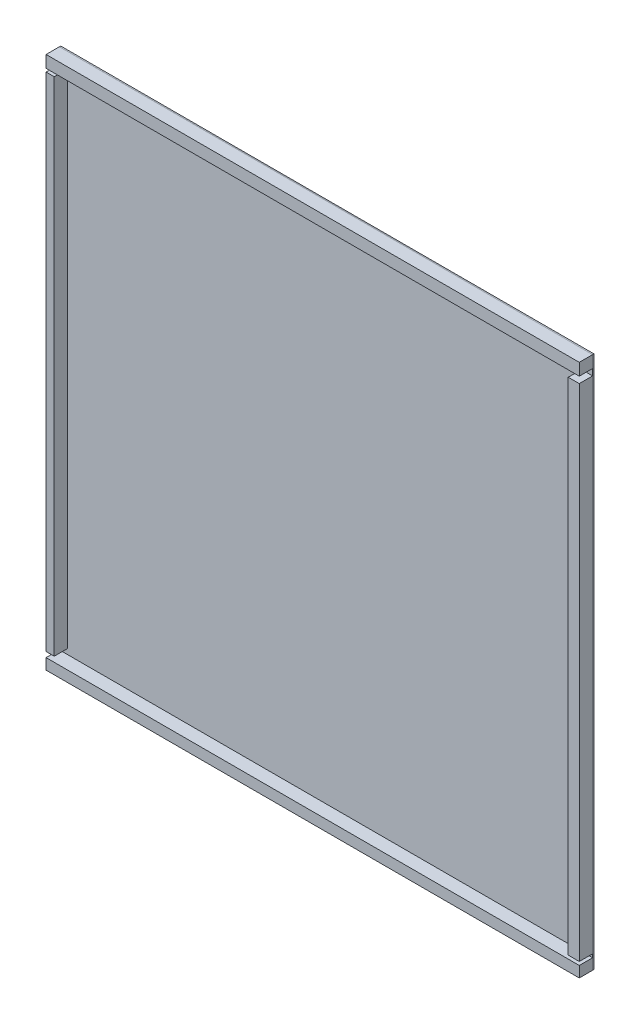
from build123d import *

# Parameters (mm, degrees)
SKETCH1_W           = 4000
SKETCH1_H           = 4000
BOSS_EXTRUDE1_DEPTH = 10
SKETCH2_W           = 4000
SKETCH2_H           = 4000
BOSS_EXTRUDE2_DEPTH = 10
SKETCH3_W           = 4000
SKETCH3_H           = 90.124072545
BOSS_EXTRUDE3_DEPTH = 100
SKETCH4_W           = 4000
SKETCH4_H           = 81.585108981
BOSS_EXTRUDE4_DEPTH = 100
SKETCH5_W           = 82.704697277
SKETCH5_H           = 3754.532371486
BOSS_EXTRUDE5_DEPTH = 100
SKETCH6_W           = 61.008409113
SKETCH6_H           = 3764.829598476
BOSS_EXTRUDE6_DEPTH = 100


with BuildPart() as part:
    # Sketch1 → Boss-Extrude1 (new body)
    with BuildSketch(Plane.XY):
        with Locations((1750, 1750)):
            Rectangle(SKETCH1_W, SKETCH1_H)
    extrude(amount=BOSS_EXTRUDE1_DEPTH)


with BuildPart() as body_2:
    # Sketch2 → Boss-Extrude2 (new body)
    with BuildSketch(Plane.XY.offset(10)):
        with Locations((1750, 1750)):
            Rectangle(SKETCH2_W, SKETCH2_H)
    extrude(amount=-BOSS_EXTRUDE2_DEPTH)


with BuildPart() as body_3:
    # Sketch3 → Boss-Extrude3 (new body)
    with BuildSketch(Plane.XY.offset(10)):
        with Locations((1750, 3704.937963728)):
            Rectangle(SKETCH3_W, SKETCH3_H)
    extrude(amount=BOSS_EXTRUDE3_DEPTH)


with BuildPart() as body_4:
    # Sketch4 → Boss-Extrude4 (new body)
    with BuildSketch(Plane.XY.offset(10)):
        with Locations((1750, -209.20744551)):
            Rectangle(SKETCH4_W, SKETCH4_H)
    extrude(amount=BOSS_EXTRUDE4_DEPTH)


with BuildPart() as body_5:
    # Sketch5 → Boss-Extrude5 (new body)
    with BuildSketch(Plane.XY.offset(10)):
        with Locations((3708.647651362, 1734.392725891)):
            Rectangle(SKETCH5_W, SKETCH5_H)
    extrude(amount=BOSS_EXTRUDE5_DEPTH)


with BuildPart() as body_6:
    # Sketch6 → Boss-Extrude6 (new body)
    with BuildSketch(Plane.XY.offset(10)):
        with Locations((-219.495795444, 1753.423394069)):
            Rectangle(SKETCH6_W, SKETCH6_H)
    extrude(amount=BOSS_EXTRUDE6_DEPTH)


solid = Compound([part.part, body_2.part, body_3.part, body_4.part, body_5.part, body_6.part])
